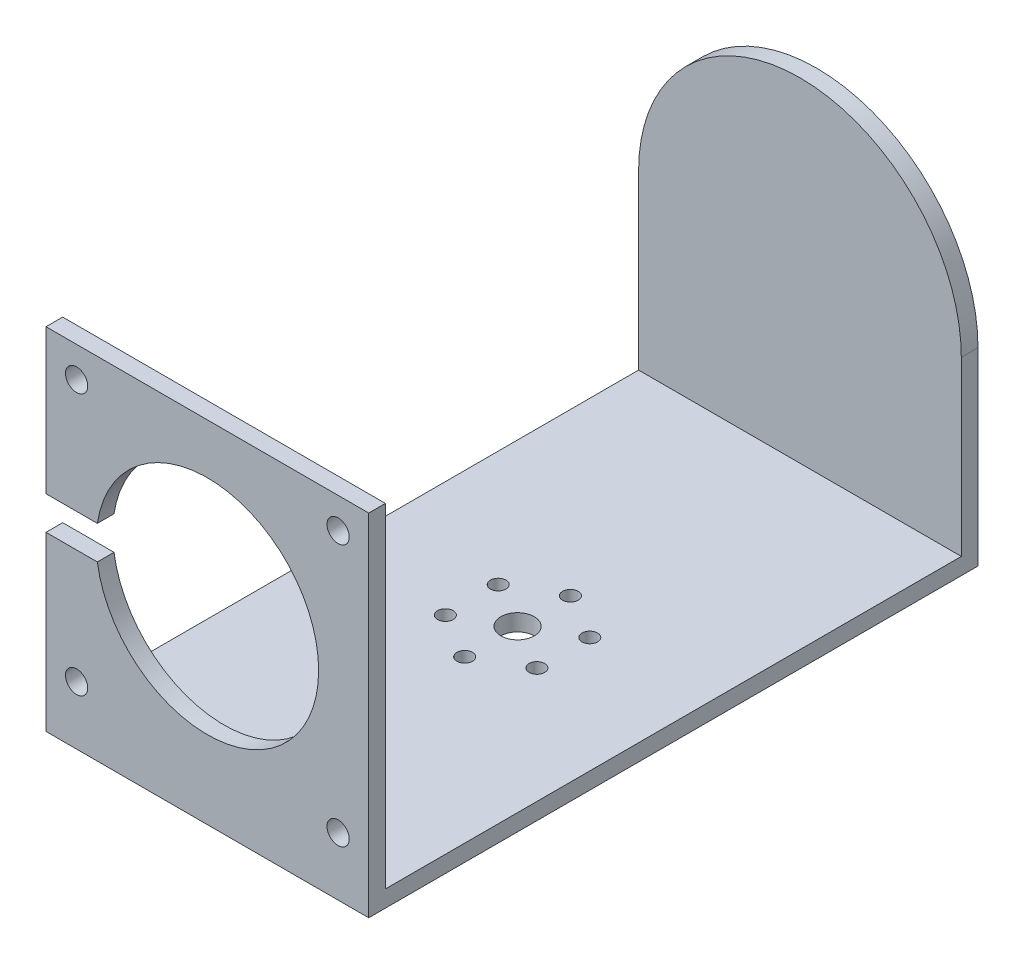
from build123d import *

# Parameters (mm, degrees)
BOSS_EXTRUDE1_DEPTH = 58
SKETCH2_R           = 2
SKETCH2_R_2         = 20
CUT_EXTRUDE1_DEPTH  = 58
CUT_EXTRUDE2_DEPTH  = 58
CUT_EXTRUDE3_DEPTH  = 58
SKETCH5_R           = 2.95
BOSS_EXTRUDE2_DEPTH = 8
SKETCH6_R           = 3
SKETCH6_R_2         = 1.4
CUT_EXTRUDE4_DEPTH  = 8
SKETCH7_W           = 29
SKETCH7_H           = 6
CUT_EXTRUDE5_DEPTH  = 10


with BuildPart() as part:
    # Sketch1 → Boss-Extrude1 (new body)
    with BuildSketch(Plane(origin=(0, 0, 0), x_dir=(0, 0, -1), z_dir=(1, 0, 0))):
        Polygon((-73.351671883, 30.400809615), (-73.351671883, -29.599190385), (30.148328117, -29.599190385), (30.148328117, 30.400809615), (33.148328117, 30.400809615), (33.148328117, -32.599190385), (-76.351671883, -32.599190385), (-76.351671883, 30.400809615), align=None)
    extrude(amount=BOSS_EXTRUDE1_DEPTH)

    # Sketch2 → Cut-Extrude1 (cut)
    with BuildSketch(Plane.XY.offset(76.351671883)):
        with Locations((5.5, 24.900809615)):
            Circle(SKETCH2_R)
        with Locations((52.5, 24.900809615)):
            Circle(SKETCH2_R)
        with Locations((52.5, -22.099190385)):
            Circle(SKETCH2_R)
        with Locations((5.5, -22.099190385)):
            Circle(SKETCH2_R)
        with Locations((29, 1.400809615)):
            Circle(SKETCH2_R_2)
    extrude(amount=-CUT_EXTRUDE1_DEPTH, mode=Mode.SUBTRACT)

    # Sketch3 → Cut-Extrude2 (cut)
    with BuildSketch(Plane(origin=(0, 0, -33.148328117), x_dir=(-1, 0, 0), z_dir=(0, 0, -1))):
        with BuildLine():
            Line((-29, 30.400809615), (-58, 30.400809615))
            Line((-58, 30.400809615), (-58, 1.400809615))
            ThreePointArc((-58, 1.400809615), (-49.506096654, 21.90690627), (-29, 30.400809615))
        make_face()
    extrude(amount=-CUT_EXTRUDE2_DEPTH, mode=Mode.SUBTRACT)

    # Sketch4 → Cut-Extrude3 (cut)
    with BuildSketch(Plane(origin=(0, 0, -33.148328117), x_dir=(-1, 0, 0), z_dir=(0, 0, -1))):
        with BuildLine():
            Line((-29, 30.400809615), (0, 30.400809615))
            Line((0, 30.400809615), (0, 1.400809615))
            ThreePointArc((0, 1.400809615), (-8.493903346, 21.90690627), (-29, 30.400809615))
        make_face()
    extrude(amount=-CUT_EXTRUDE3_DEPTH, mode=Mode.SUBTRACT)

    # Sketch5 → Boss-Extrude2 (add)
    with BuildSketch(Plane(origin=(0, 0, -33.148328117), x_dir=(-1, 0, 0), z_dir=(0, 0, -1))):
        with Locations((-29, 1.400809615)):
            Circle(SKETCH5_R)
    extrude(amount=BOSS_EXTRUDE2_DEPTH)

    # Sketch6 → Cut-Extrude4 (cut)
    with BuildSketch(Plane.XZ.offset(32.599190385)):
        with Locations((29, 20.601671883)):
            Circle(SKETCH6_R)
        with Locations((29, 30.101671883)):
            Circle(SKETCH6_R_2)
        with Locations((37.227241336, 25.351671883)):
            Circle(SKETCH6_R_2)
        with Locations((37.227241336, 15.851671883)):
            Circle(SKETCH6_R_2)
        with Locations((29, 11.101671883)):
            Circle(SKETCH6_R_2)
        with Locations((20.772758664, 15.851671883)):
            Circle(SKETCH6_R_2)
        with Locations((20.772758664, 25.351671883)):
            Circle(SKETCH6_R_2)
    extrude(amount=-CUT_EXTRUDE4_DEPTH, mode=Mode.SUBTRACT)

    # Sketch7 → Cut-Extrude5 (cut)
    with BuildSketch(Plane.XY.offset(76.351671883)):
        with Locations((14.5, 1.400809615)):
            Rectangle(SKETCH7_W, SKETCH7_H)
    extrude(amount=-CUT_EXTRUDE5_DEPTH, mode=Mode.SUBTRACT)


solid = part.part
